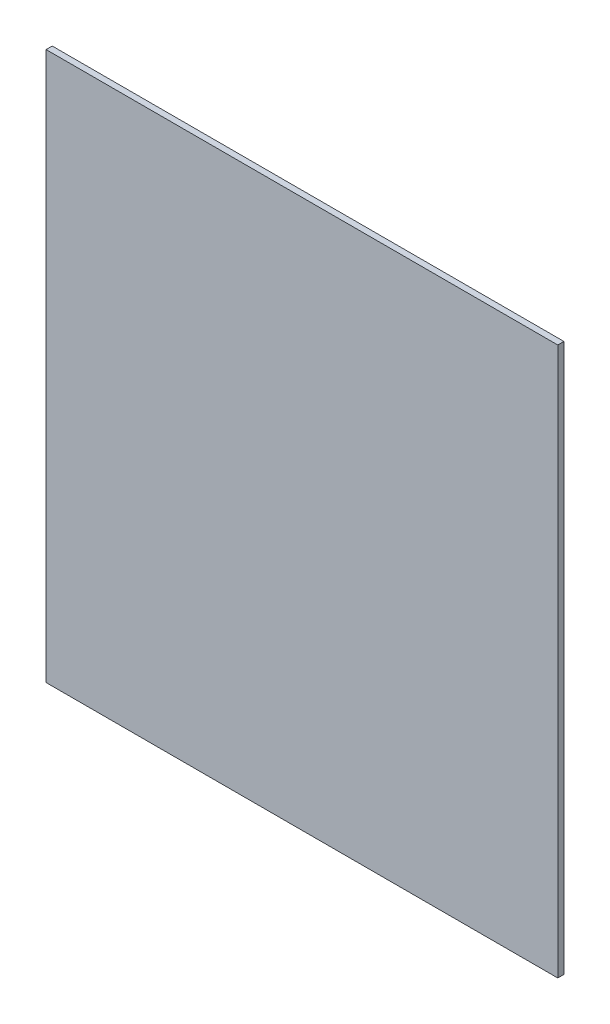
from build123d import *

# Parameters (mm, degrees)
SKETCH1_W           = 249.6
SKETCH1_H           = 267.4
BOSS_EXTRUDE1_DEPTH = 3


with BuildPart() as part:
    # Sketch1 → Boss-Extrude1 (new body)
    with BuildSketch(Plane.XY):
        with Locations((124.8, -133.7)):
            Rectangle(SKETCH1_W, SKETCH1_H)
    extrude(amount=BOSS_EXTRUDE1_DEPTH)


solid = part.part
